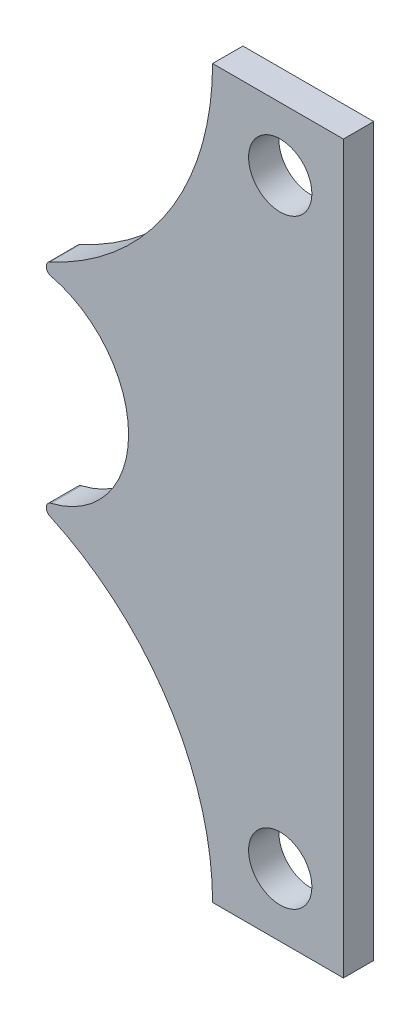
from build123d import *

# Parameters (mm, degrees)
SKETCH1_R           = 6.3627
BOSS_EXTRUDE1_DEPTH = 3.048
FILLET1_R           = 1.27


with BuildPart() as part:
    # Sketch1 → Boss-Extrude1 (new body, symmetric)
    with BuildSketch(Plane.XY):
        with BuildLine():
            ThreePointArc((-44.45, -20.32), (-30.440021806, -27.674009584), (-19.05, -38.657103373))
            Line((-19.05, -38.657103373), (-19.05, 38.657103373))
            ThreePointArc((-19.05, 38.657103373), (-30.440021806, 27.674009584), (-44.45, 20.32))
            ThreePointArc((-44.45, 20.32), (-30.081590206, 14.368409794), (-24.13, 0))
            ThreePointArc((-24.13, 0), (-30.081590206, -14.368409794), (-44.45, -20.32))
        make_face()
        with BuildLine():
            ThreePointArc((-19.05, -38.657103373), (-17.322621511, -40.998313496), (-15.719319348, -43.426177466))
            ThreePointArc((-15.719319348, -43.426177466), (1.415517775, -24.650338319), (7.62, 0))
            ThreePointArc((7.62, 0), (1.415517775, 24.650338319), (-15.719319348, 43.426177466))
            ThreePointArc((-15.719319348, 43.426177466), (-17.322621511, 40.998313496), (-19.05, 38.657103373))
            Line((-19.05, 38.657103373), (-19.05, -38.657103373))
        make_face()
        with BuildLine():
            ThreePointArc((-15.719319348, -43.426177466), (-9.406121761, -57.631125381), (-7.246114065, -73.025))
            Line((-7.246114065, -73.025), (19.05, -73.025))
            Line((19.05, -73.025), (19.05, 73.025))
            Line((19.05, 73.025), (-7.246114065, 73.025))
            ThreePointArc((-7.246114065, 73.025), (-9.406121761, 57.631125381), (-15.719319348, 43.426177466))
            ThreePointArc((-15.719319348, 43.426177466), (1.415517775, 24.650338319), (7.62, 0))
            ThreePointArc((7.62, 0), (1.415517775, -24.650338319), (-15.719319348, -43.426177466))
        make_face()
        with Locations((6.35, -60.325)):
            Circle(SKETCH1_R, mode=Mode.SUBTRACT)
        with Locations((6.35, 60.325)):
            Circle(SKETCH1_R, mode=Mode.SUBTRACT)
    extrude(amount=BOSS_EXTRUDE1_DEPTH, both=True)

    # Fillet1
    fillet1_edges = [part.edges().sort_by_distance(p)[0] for p in [
        (-44.45, -20.32, 0),
        (-44.45, 20.32, 0),
    ]]
    fillet(fillet1_edges, radius=FILLET1_R)


solid = part.part
